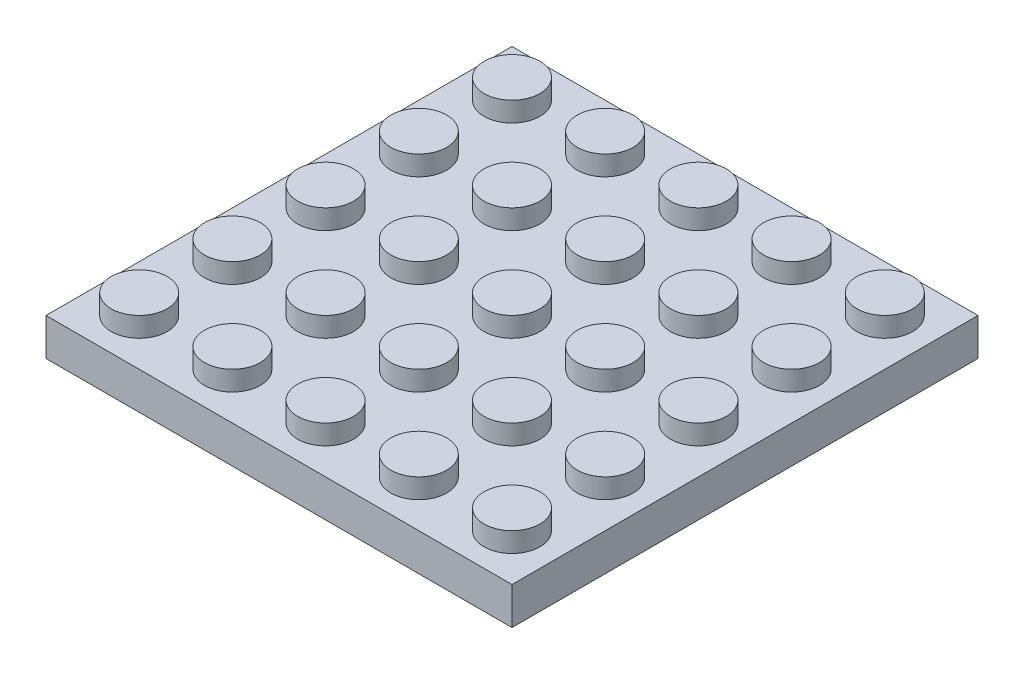
from build123d import *

# Parameters (mm, degrees)
SKETCH_1_W                  = 8
SKETCH_1_H                  = 8
HEIGHT_DEPTH                = 3.2
SKETCH_2_R                  = 2.4
EXTRUDE_2_DEPTH             = 1.7
PATTERN_LINEAR_1_COUNT      = 5
PATTERN_LINEAR_1_PITCH      = 8
PATTERN_LINEAR_1_COUNT_DIR2 = 5
PATTERN_LINEAR_1_PITCH_DIR2 = 8
SHELL_1_T                   = -1.6
SKETCH_3_R                  = 3.255
SKETCH_3_R_2                = 2.4
EXTRUDE_3_DEPTH             = 1.6
PATTERN_LINEAR_2_COUNT      = 4
PATTERN_LINEAR_2_PITCH      = 8
PATTERN_LINEAR_2_COUNT_DIR2 = 4
PATTERN_LINEAR_2_PITCH_DIR2 = 8


with BuildPart() as part:
    # 草圖1 → height (new body)
    with BuildSketch(Plane(origin=(0, 0, 0), x_dir=(1, 0, 0), z_dir=(0, 1, 0))):
        Rectangle(SKETCH_1_W, SKETCH_1_H)
    height = extrude(amount=HEIGHT_DEPTH)

    # 草圖2 → 填料-伸長2 (add)
    with BuildSketch(Plane(origin=(0, 3.2, 0), x_dir=(1, 0, 0), z_dir=(0, 1, 0))):
        Circle(SKETCH_2_R)
    extrude_2 = extrude(amount=EXTRUDE_2_DEPTH)

    # 直線複製排列1: height, Extrude 2 5 × 5
    with Locations(*[(i * PATTERN_LINEAR_1_PITCH, 0, j * PATTERN_LINEAR_1_PITCH_DIR2) for i in range(PATTERN_LINEAR_1_COUNT) for j in range(PATTERN_LINEAR_1_COUNT_DIR2) if (i, j) != (0, 0)]):
        add(height)
        add(extrude_2)

    # 薄殼1
    shell_1_openings = [part.faces().sort_by_distance(p)[0] for p in [
        (16, 0, 16),
    ]]
    offset(amount=SHELL_1_T, openings=shell_1_openings, kind=Kind.INTERSECTION)

    # 草圖3 → 填料-伸長3 (add)
    with BuildSketch(Plane.XZ.offset(-1.6)):
        with Locations((4, 4)):
            Circle(SKETCH_3_R)
        with Locations((4, 4)):
            Circle(SKETCH_3_R_2, mode=Mode.SUBTRACT)
    extrude_3 = extrude(amount=EXTRUDE_3_DEPTH)

    # 直線複製排列2: Extrude 3 4 × 4
    with Locations(*[(j * PATTERN_LINEAR_2_PITCH_DIR2, 0, i * PATTERN_LINEAR_2_PITCH) for i in range(PATTERN_LINEAR_2_COUNT) for j in range(PATTERN_LINEAR_2_COUNT_DIR2) if (i, j) != (0, 0)]):
        add(extrude_3)


solid = part.part
